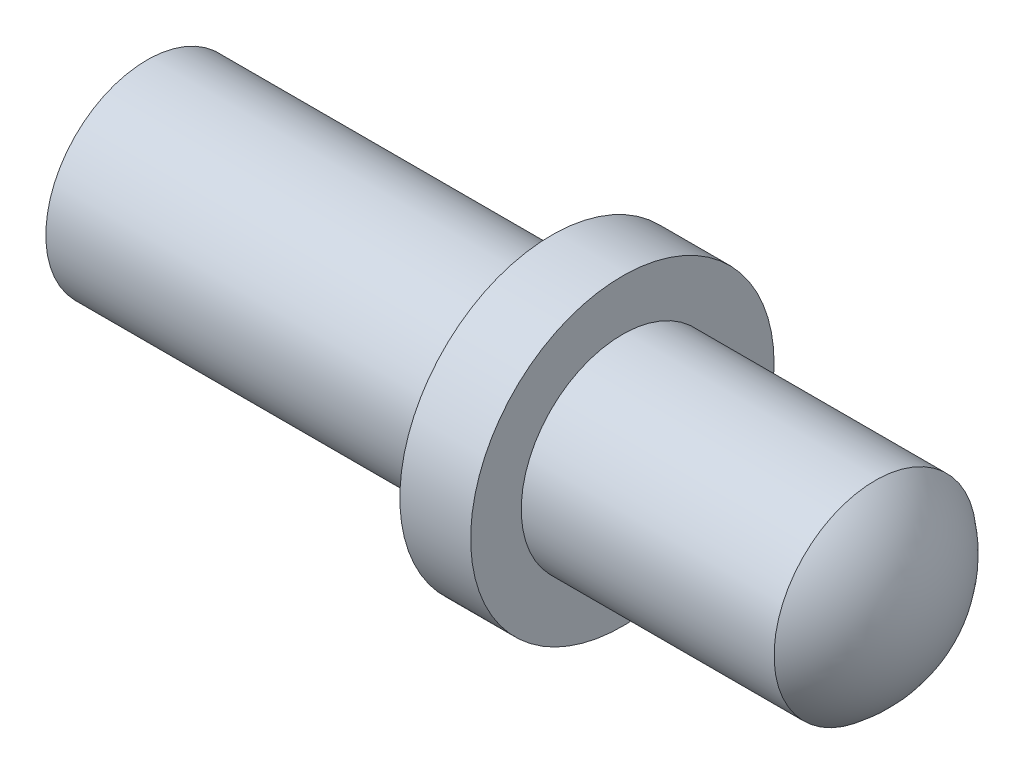
from build123d import *

# Parameters (mm, degrees)
D_ME1_FACE_RADIUS = 2
D_ME1_HEIGHT      = 1


with BuildPart() as part:
    # Esquisse1 → R_volution1 (revolve)
    with BuildSketch(Plane.XY):
        Polygon((0, 0), (0, 2), (8, 2), (8, 3), (9.4, 3), (9.4, 2), (14.4, 2), (14.4, 0), align=None)
    revolve(axis=Axis((14.4, 0, 0), (-1, 0, 0)))

    # D_me1: a dome of height H over a round flat face of radius A is a cap of a sphere of radius (A * A + H * H) / (2 * H)
    d_me1_r = (D_ME1_FACE_RADIUS * D_ME1_FACE_RADIUS + D_ME1_HEIGHT * D_ME1_HEIGHT) / (2 * D_ME1_HEIGHT)
    d_me1_base = Plane((14.4, 0, 0), z_dir=(1, 0, 0))
    with Locations(d_me1_base.offset(D_ME1_HEIGHT - d_me1_r)):
        d_me1_ball = Sphere(d_me1_r, mode=Mode.PRIVATE)
    add(split(d_me1_ball, bisect_by=d_me1_base, keep=Keep.TOP, mode=Mode.PRIVATE))


solid = part.part
